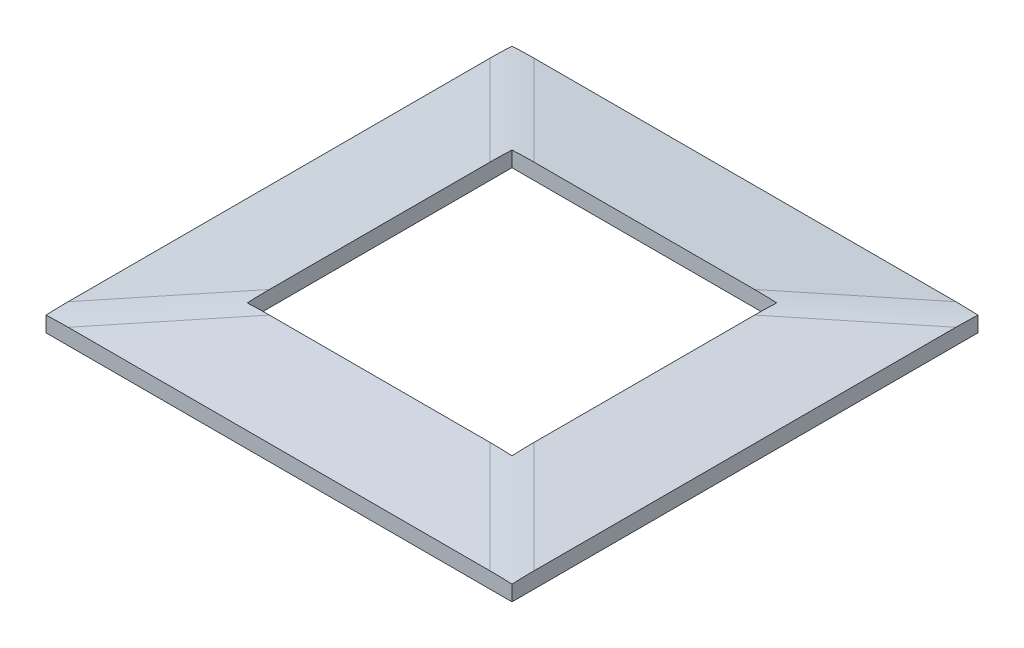
from build123d import *

# Parameters (mm, degrees)
EXTRUDE_1_DEPTH     = 44
SKETCH_2_OUTSIDE_W  = 114.91
SKETCH_2_OUTSIDE_H  = 31.91
CUT_EXTRUDE_1_DEPTH = 44
SKETCH_3_W          = 83
SKETCH_3_H          = 84.111264856
CUT_EXTRUDE_2_DEPTH = 2
SKETCH_5_W          = 50
SKETCH_5_H          = 50
CUT_EXTRUDE_3_DEPTH = 6
FILLET_1_R          = 40


with BuildPart() as part:
    # Эскиз1 → Бобышка-Вытянуть1 (new body, symmetric)
    with BuildSketch(Plane(origin=(0, 0, 0), x_dir=(0, 0, -1), z_dir=(1, 0, 0))):
        Polygon((44, 0), (-44, 0), (-44, 3), (-25, 5), (25, 5), (44, 3), align=None)
    extrude(amount=EXTRUDE_1_DEPTH, both=True)

    # Эскиз2 outside → Вырез-Вытянуть1 (cut, symmetric)
    with BuildSketch(Plane.XY):
        with Locations((0, 2.5)):
            Rectangle(SKETCH_2_OUTSIDE_W, SKETCH_2_OUTSIDE_H)
        Polygon((44, 0), (-44, 0), (-44, 3), (-25, 5), (25, 5), (44, 3), align=None, mode=Mode.SUBTRACT)
    extrude(amount=CUT_EXTRUDE_1_DEPTH, both=True, mode=Mode.SUBTRACT)

    # Эскиз3 → Вырез-Вытянуть2 (cut)
    with BuildSketch(Plane.XZ):
        Rectangle(SKETCH_3_W, SKETCH_3_H)
    extrude(amount=-CUT_EXTRUDE_2_DEPTH, mode=Mode.SUBTRACT)

    # Эскиз5 → Вырез-Вытянуть3 (cut, through all)
    with BuildSketch(Plane.XZ):
        Rectangle(SKETCH_5_W, SKETCH_5_H)
    extrude(amount=-CUT_EXTRUDE_3_DEPTH, mode=Mode.SUBTRACT)

    # Скругление1
    fillet_1_edges = [part.edges().sort_by_distance(p)[0] for p in [
        (34.5, 4, -34.5),
        (-34.5, 4, -34.5),
        (-34.5, 4, 34.5),
        (34.5, 4, 34.5),
    ]]
    fillet(fillet_1_edges, radius=FILLET_1_R)


solid = part.part
